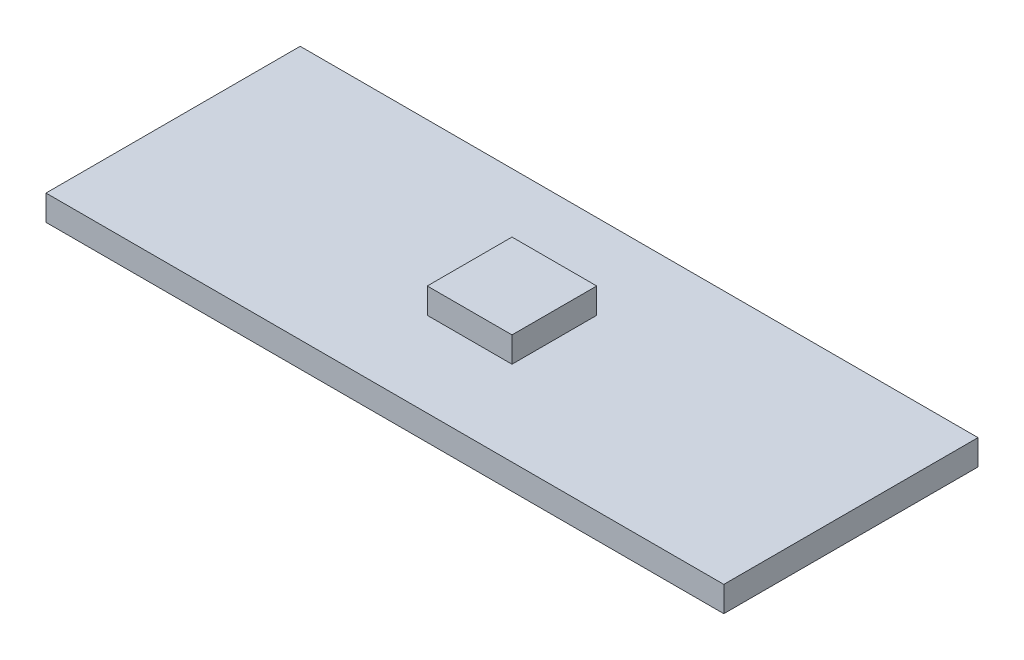
from build123d import *

# Parameters (mm, degrees)
SKETCH_1_W      = 40
SKETCH_1_H      = 15
EXTRUDE_1_DEPTH = 1.5
SKETCH_2_W      = 5
SKETCH_2_H      = 5
EXTRUDE_2_DEPTH = 1.5


with BuildPart() as part:
    # 草图1 → 凸台-拉伸1 (new body)
    with BuildSketch(Plane(origin=(0, 0, 0), x_dir=(1, 0, 0), z_dir=(0, 1, 0))):
        Rectangle(SKETCH_1_W, SKETCH_1_H)
    extrude(amount=EXTRUDE_1_DEPTH)

    # 草图2 → 凸台-拉伸2 (add)
    with BuildSketch(Plane(origin=(0, 1.5, 0), x_dir=(1, 0, 0), z_dir=(0, 1, 0))):
        Rectangle(SKETCH_2_W, SKETCH_2_H)
    extrude(amount=EXTRUDE_2_DEPTH)


solid = part.part
